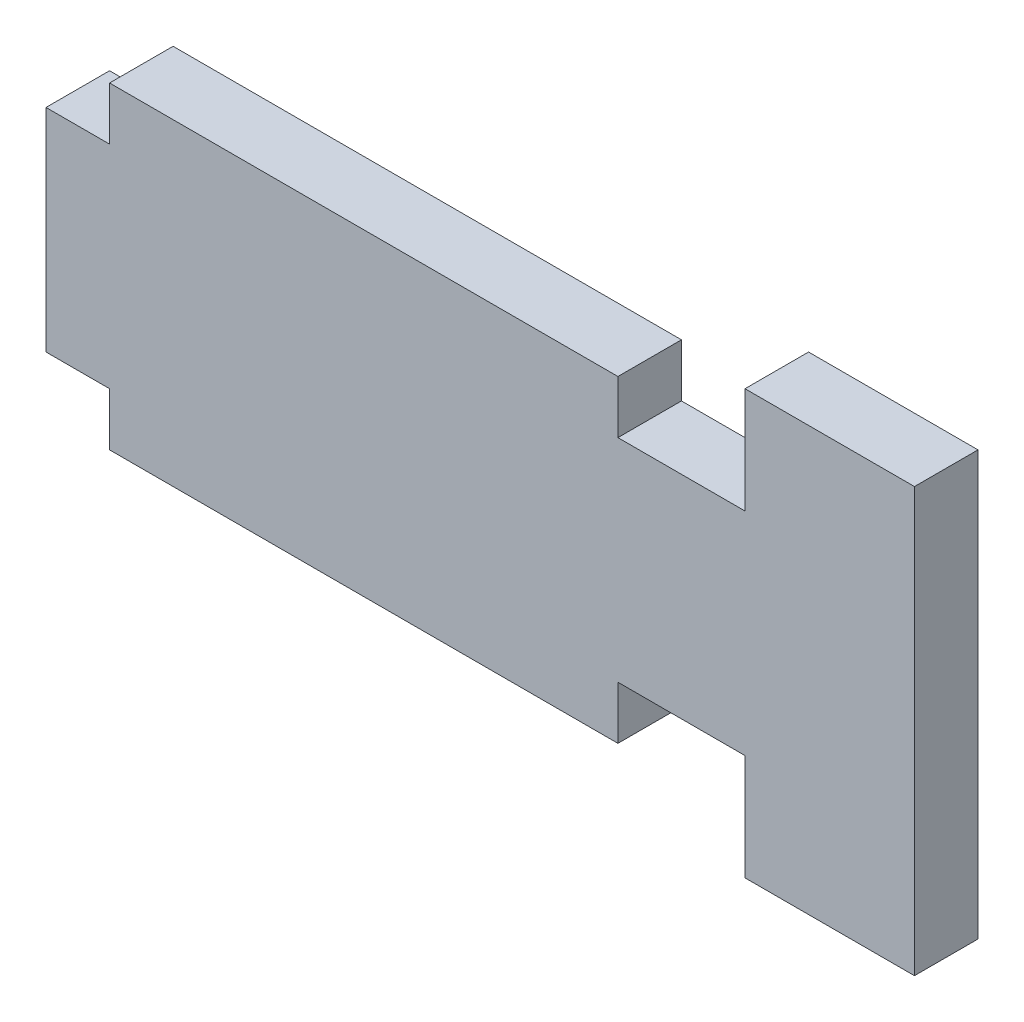
from build123d import *

# Parameters (mm, degrees)
ESBO_O1_W                = 3
ESBO_O1_H                = 10
ESBO_O1_W_2              = 6
RESSALTO_EXTRUS_O1_DEPTH = 3


with BuildPart() as part:
    # Esboço1 → Ressalto-extrusão1 (new body)
    with BuildSketch(Plane.XY):
        Polygon((-12, -5), (-12, -7.5), (12, -7.5), (12, -5), (12, 5), (12, 7.5), (-12, 7.5), (-12, 5), align=None)
        with Locations((-13.5, 0)):
            Rectangle(ESBO_O1_W, ESBO_O1_H)
        with Locations((15, 0)):
            Rectangle(ESBO_O1_W_2, ESBO_O1_H)
        Polygon((18, 5), (18, -5), (18, -10), (26, -10), (26, 10), (18, 10), align=None)
    extrude(amount=RESSALTO_EXTRUS_O1_DEPTH)


solid = part.part
